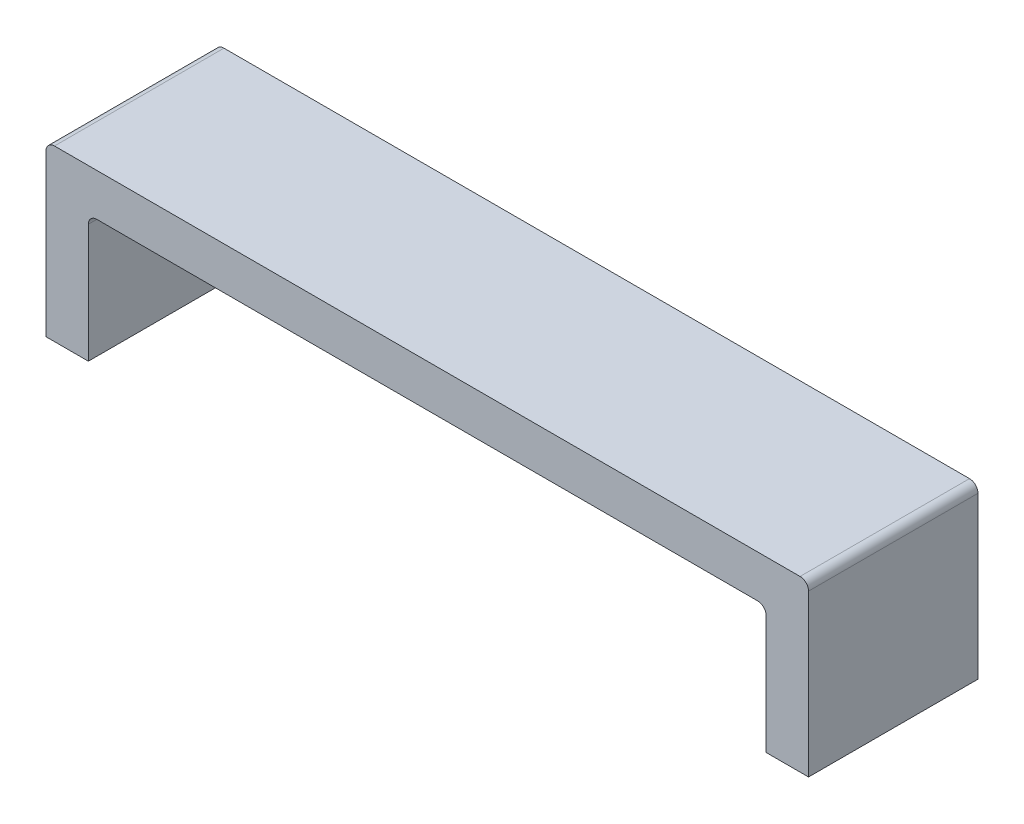
from build123d import *

# Parameters (mm, degrees)
BOSS_EXTRUDE1_DEPTH = 101.6
FILLET1_R           = 5.08


with BuildPart() as part:
    # Sketch1 → Boss-Extrude1 (new body)
    with BuildSketch(Plane.XY):
        Polygon((0, 0), (0, 101.6), (457.2, 101.6), (457.2, 0), (431.8, 0), (431.8, 76.2), (25.4, 76.2), (25.4, 0), align=None)
    extrude(amount=BOSS_EXTRUDE1_DEPTH)

    # Fillet1
    fillet1_edges = [part.edges().sort_by_distance(p)[0] for p in [
        (0, 101.6, 50.8),
        (457.2, 101.6, 50.8),
        (431.8, 76.2, 50.8),
        (25.4, 76.2, 50.8),
    ]]
    fillet(fillet1_edges, radius=FILLET1_R)


solid = part.part
